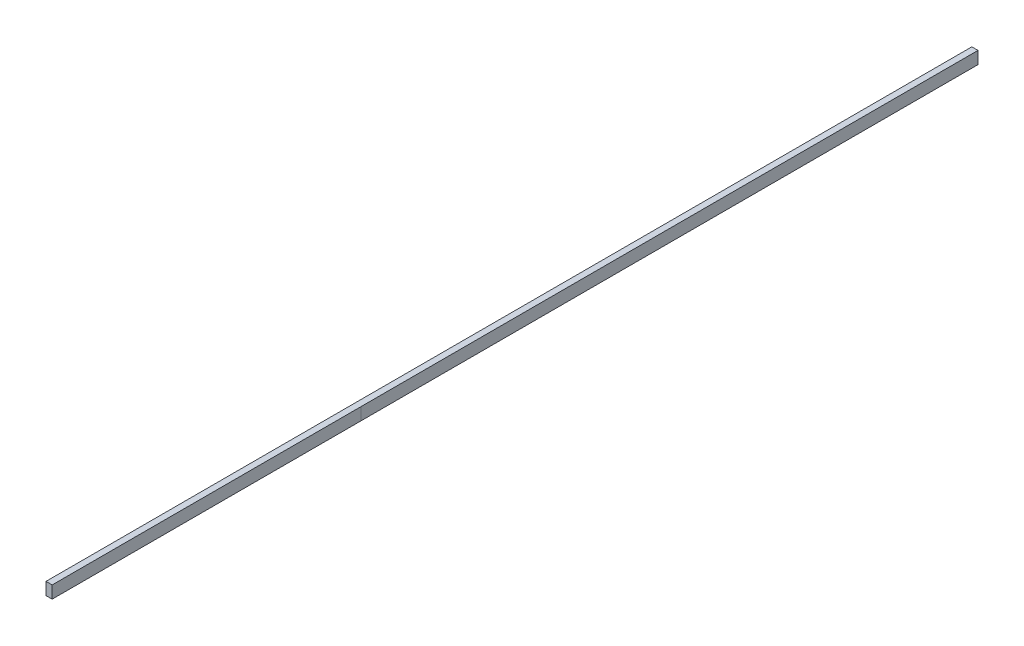
from build123d import *

# Parameters (mm, degrees)
SKETCH1_W           = 10
SKETCH1_H           = 20
BOSS_EXTRUDE1_DEPTH = 1500


with BuildPart() as part:
    # Sketch1 → Boss-Extrude1 (new body)
    with BuildSketch(Plane.XY):
        with Locations((5, 10)):
            Rectangle(SKETCH1_W, SKETCH1_H)
    extrude(amount=BOSS_EXTRUDE1_DEPTH)


solid = part.part
